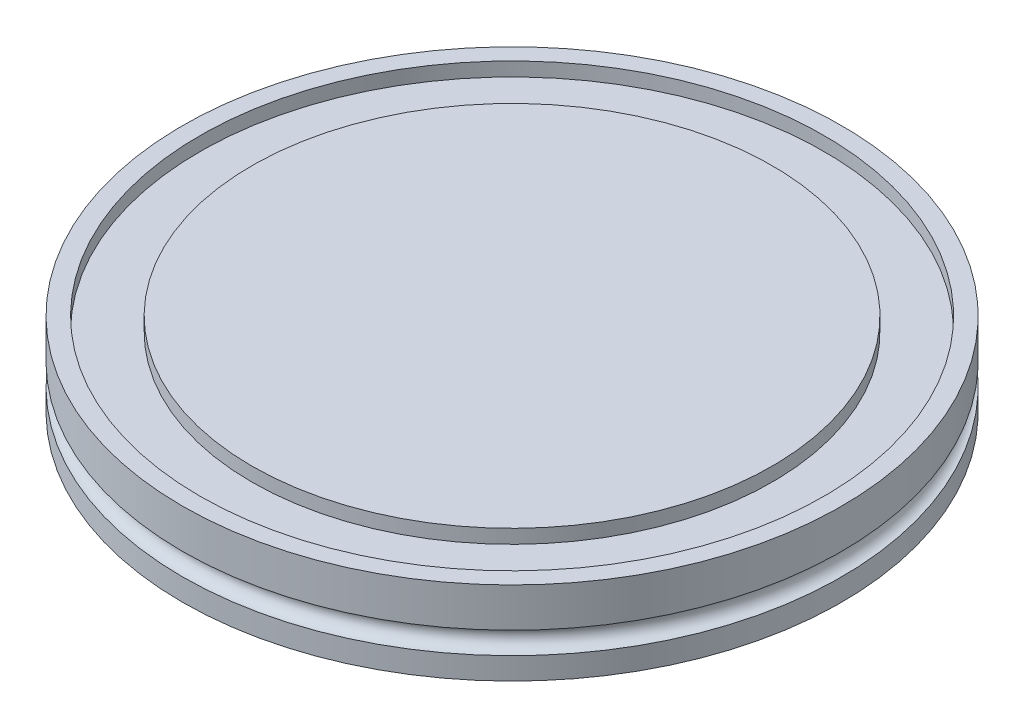
from build123d import *


with BuildPart() as part:
    # Sketch1 → Revolve1 (revolve)
    with BuildSketch(Plane.XY):
        with BuildLine():
            Line((-35, 0), (-47.5, 0))
            Line((-47.5, 0), (-47.5, 3.175))
            ThreePointArc((-47.5, 3.175), (-45.9125, 4.7625), (-47.5, 6.35))
            Line((-47.5, 6.35), (-47.5, 12))
            Line((-47.5, 12), (-45, 12))
            Line((-45, 12), (-45, 10))
            Line((-45, 10), (-37.5, 10))
            Line((-37.5, 10), (-37.5, 12))
            Line((-37.5, 12), (0, 12))
            Line((0, 12), (0, 0))
            Line((0, 0), (-28.65, 0))
            Line((-28.65, 0), (-28.65, 3.8))
            Line((-28.65, 3.8), (-35, 3.8))
            Line((-35, 3.8), (-35, 0))
        make_face()
    revolve(axis=Axis((0, 0, 0), (0, -1, 0)))


solid = part.part
